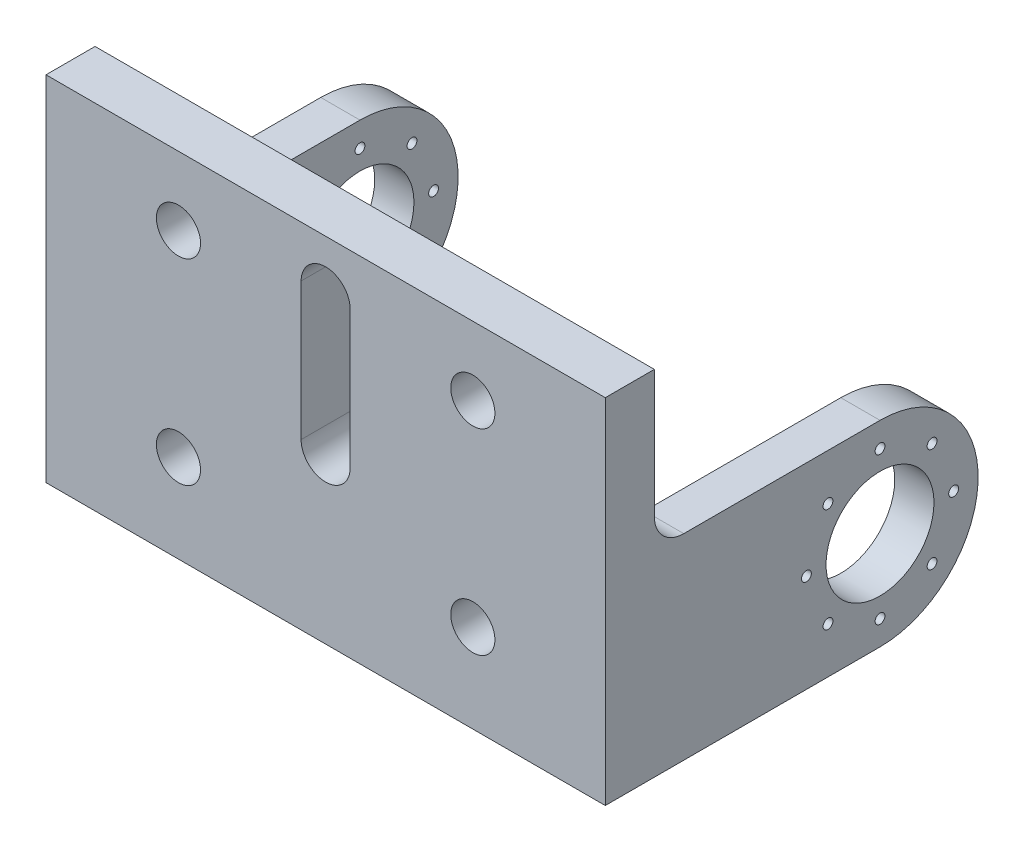
from build123d import *

# Parameters (mm, degrees)
SKETCH1_W            = 57
SKETCH1_H            = 36
BOSS_EXTRUDE1_DEPTH  = 5
SKETCH3_W            = 23
SKETCH3_H            = 20
BOSS_EXTRUDE3_DEPTH  = 4
BOSS_EXTRUDE4_DEPTH  = 4
FILLET1_R            = 3
CUT_EXTRUDE1_REACH   = 40
SKETCH6_R            = 5.5
CUT_EXTRUDE2_DEPTH   = 58
SKETCH7_R            = 0.5
CUT_EXTRUDE3_DEPTH   = 58
CIRPATTERN1_COUNT    = 8
SKETCH8_R            = 2.25
CUT_EXTRUDE4_DEPTH   = 5
LPATTERN1_COUNT      = 2
LPATTERN1_PITCH      = 30
LPATTERN1_COUNT_DIR2 = 2
LPATTERN1_PITCH_DIR2 = 20


with BuildPart() as part:
    # Sketch1 → Boss-Extrude1 (new body)
    with BuildSketch(Plane.XY):
        Rectangle(SKETCH1_W, SKETCH1_H)
    extrude(amount=-BOSS_EXTRUDE1_DEPTH)

    # Sketch3 → Boss-Extrude3 (add)
    with BuildSketch(Plane.ZY.offset(28.5)):
        with Locations((-16.5, -8)):
            Rectangle(SKETCH3_W, SKETCH3_H)
    boss_extrude3 = extrude(amount=-BOSS_EXTRUDE3_DEPTH)

    # Sketch4 → Boss-Extrude4 (add)
    with BuildSketch(Plane.ZY.offset(28.5)):
        with BuildLine():
            Line((-28, 2), (-28, -18))
            ThreePointArc((-28, -18), (-38, -8), (-28, 2))
        make_face()
    boss_extrude4 = extrude(amount=-BOSS_EXTRUDE4_DEPTH)

    # Mirror1: Boss-Extrude3, Boss-Extrude4 across plane
    add(boss_extrude3.mirror(Plane(origin=(0, 0, 0), x_dir=(0, 0, 1), z_dir=(1, 0, 0))))
    add(boss_extrude4.mirror(Plane(origin=(0, 0, 0), x_dir=(0, 0, 1), z_dir=(1, 0, 0))))

    # Fillet1
    fillet1_edges = [part.edges().sort_by_distance(p)[0] for p in [
        (26.5, 2, -5),
        (-26.5, 2, -5),
    ]]
    fillet(fillet1_edges, radius=FILLET1_R)

    # Sketch5 → Cut-Extrude1 (cut, up to next)
    with BuildSketch(Plane.XY, mode=Mode.PRIVATE) as cut_extrude1_sk1:
        with BuildLine():
            Line((-2.5, -1.2), (-2.5, 12.8))
            ThreePointArc((-2.5, 12.8), (0, 15.3), (2.5, 12.8))
            Line((2.5, 12.8), (2.5, -1.2))
            ThreePointArc((2.5, -1.2), (0, -3.7), (-2.5, -1.2))
        make_face()
    cut_extrude1_tool1 = extrude(cut_extrude1_sk1.sketch, amount=-CUT_EXTRUDE1_REACH, mode=Mode.PRIVATE) & part.part
    add(cut_extrude1_tool1.solids().sort_by_distance((0, 5.8, 0))[0], mode=Mode.SUBTRACT)

    # Sketch6 → Cut-Extrude2 (cut, through all)
    with BuildSketch(Plane(origin=(28.5, 0, 0), x_dir=(0, 0, -1), z_dir=(1, 0, 0))):
        with Locations((28, -8)):
            Circle(SKETCH6_R)
    extrude(amount=-CUT_EXTRUDE2_DEPTH, mode=Mode.SUBTRACT)

    # Sketch7 → Cut-Extrude3 (cut, through all)
    with BuildSketch(Plane(origin=(28.5, 0, 0), x_dir=(0, 0, -1), z_dir=(1, 0, 0))):
        with Locations((20.5, -8)):
            Circle(SKETCH7_R)
    cut_extrude3 = extrude(amount=-CUT_EXTRUDE3_DEPTH, mode=Mode.SUBTRACT)

    # CirPattern1: Cut-Extrude3 ×8 about axis
    cirpattern1_axis = Axis((0, -8, -28), (1, 0, 0))
    for i in range(1, CIRPATTERN1_COUNT):
        add(cut_extrude3.rotate(cirpattern1_axis, i * 360 / CIRPATTERN1_COUNT), mode=Mode.SUBTRACT)

    # Sketch8 → Cut-Extrude4 (cut)
    with BuildSketch(Plane.XY):
        with Locations((-15, 11)):
            Circle(SKETCH8_R)
    cut_extrude4 = extrude(amount=-CUT_EXTRUDE4_DEPTH, mode=Mode.SUBTRACT)

    # LPattern1: Cut-Extrude4 2 × 2
    with Locations(*[(i * LPATTERN1_PITCH, -j * LPATTERN1_PITCH_DIR2, 0) for i in range(LPATTERN1_COUNT) for j in range(LPATTERN1_COUNT_DIR2) if (i, j) != (0, 0)]):
        add(cut_extrude4, mode=Mode.SUBTRACT)


solid = part.part
